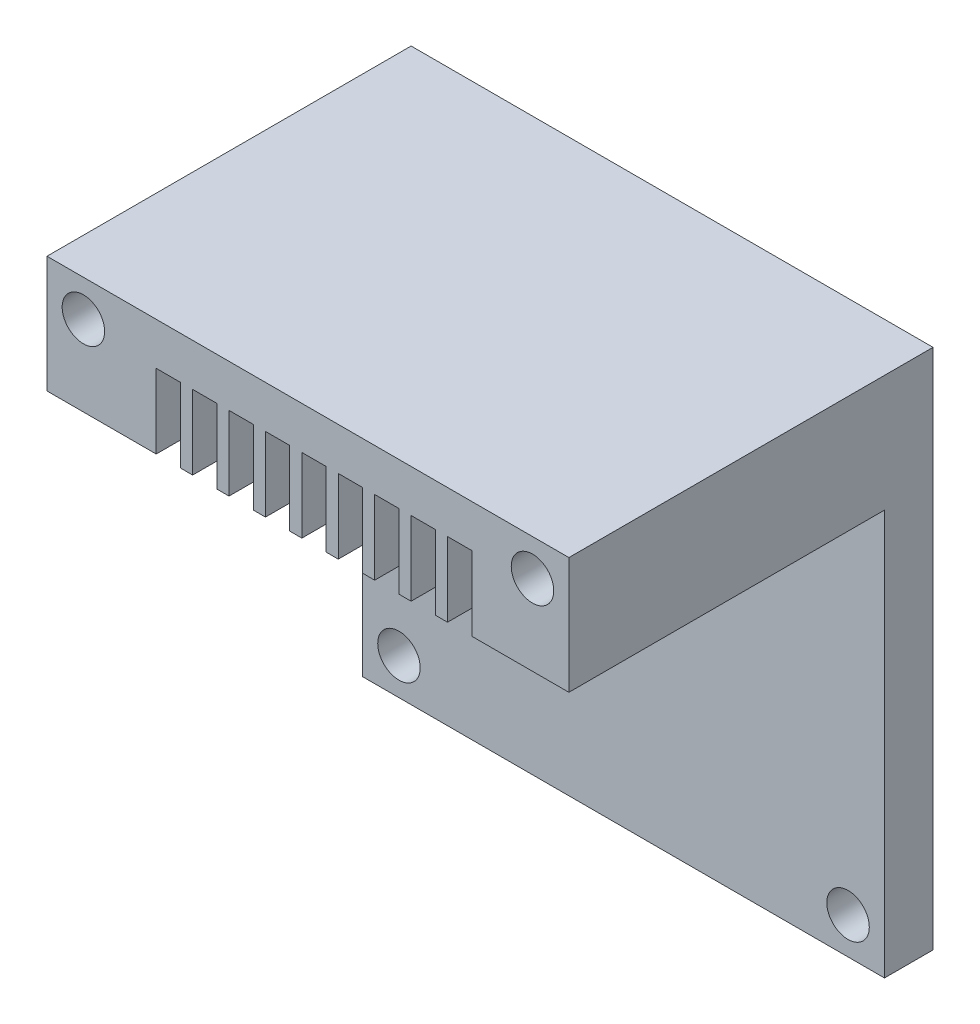
from build123d import *

# Parameters (mm, degrees)
SKETCH_1_W          = 43
SKETCH_1_H          = 43
SKETCH_1_R          = 1.75
EXTRUDE_1_DEPTH     = 30
SKETCH_2_W          = 43
SKETCH_2_H          = 33.384643537
SKETCH_2_R          = 1.75
CUT_EXTRUDE_1_DEPTH = 26
SKETCH_3_W          = 2
SKETCH_3_H          = 6.115356463
CUT_EXTRUDE_2_DEPTH = 26


with BuildPart() as part:
    # 草图1 → 凸台-拉伸1 (new body)
    with BuildSketch(Plane.XY):
        Rectangle(SKETCH_1_W, SKETCH_1_H)
        with Locations((-18.5, 18.5)):
            Circle(SKETCH_1_R, mode=Mode.SUBTRACT)
        with Locations((-18.5, -18.5)):
            Circle(SKETCH_1_R, mode=Mode.SUBTRACT)
        with Locations((18.5, -18.5)):
            Circle(SKETCH_1_R, mode=Mode.SUBTRACT)
        with Locations((18.5, 18.5)):
            Circle(SKETCH_1_R, mode=Mode.SUBTRACT)
    extrude(amount=EXTRUDE_1_DEPTH)

    # 草图2 → 切除-拉伸1 (cut)
    with BuildSketch(Plane.XY.offset(30)):
        with Locations((0, -4.807678231)):
            Rectangle(SKETCH_2_W, SKETCH_2_H)
        with Locations((-18.5, -18.5)):
            Circle(SKETCH_2_R, mode=Mode.SUBTRACT)
        with Locations((18.5, -18.5)):
            Circle(SKETCH_2_R, mode=Mode.SUBTRACT)
    extrude(amount=-CUT_EXTRUDE_1_DEPTH, mode=Mode.SUBTRACT)

    # 草图3 → 切除-拉伸2 (cut)
    with BuildSketch(Plane.XY.offset(30)):
        with Locations((-11.5, 14.942321769)):
            Rectangle(SKETCH_3_W, SKETCH_3_H)
        with Locations((-8.5, 14.942321769)):
            Rectangle(SKETCH_3_W, SKETCH_3_H)
        with Locations((-5.5, 14.942321769)):
            Rectangle(SKETCH_3_W, SKETCH_3_H)
        with Locations((-2.5, 14.942321769)):
            Rectangle(SKETCH_3_W, SKETCH_3_H)
        with Locations((0.5, 14.942321769)):
            Rectangle(SKETCH_3_W, SKETCH_3_H)
        with Locations((3.5, 14.942321769)):
            Rectangle(SKETCH_3_W, SKETCH_3_H)
        with Locations((6.5, 14.942321769)):
            Rectangle(SKETCH_3_W, SKETCH_3_H)
        with Locations((9.5, 14.942321769)):
            Rectangle(SKETCH_3_W, SKETCH_3_H)
        with Locations((12.5, 14.942321769)):
            Rectangle(SKETCH_3_W, SKETCH_3_H)
    extrude(amount=-CUT_EXTRUDE_2_DEPTH, mode=Mode.SUBTRACT)


solid = part.part
